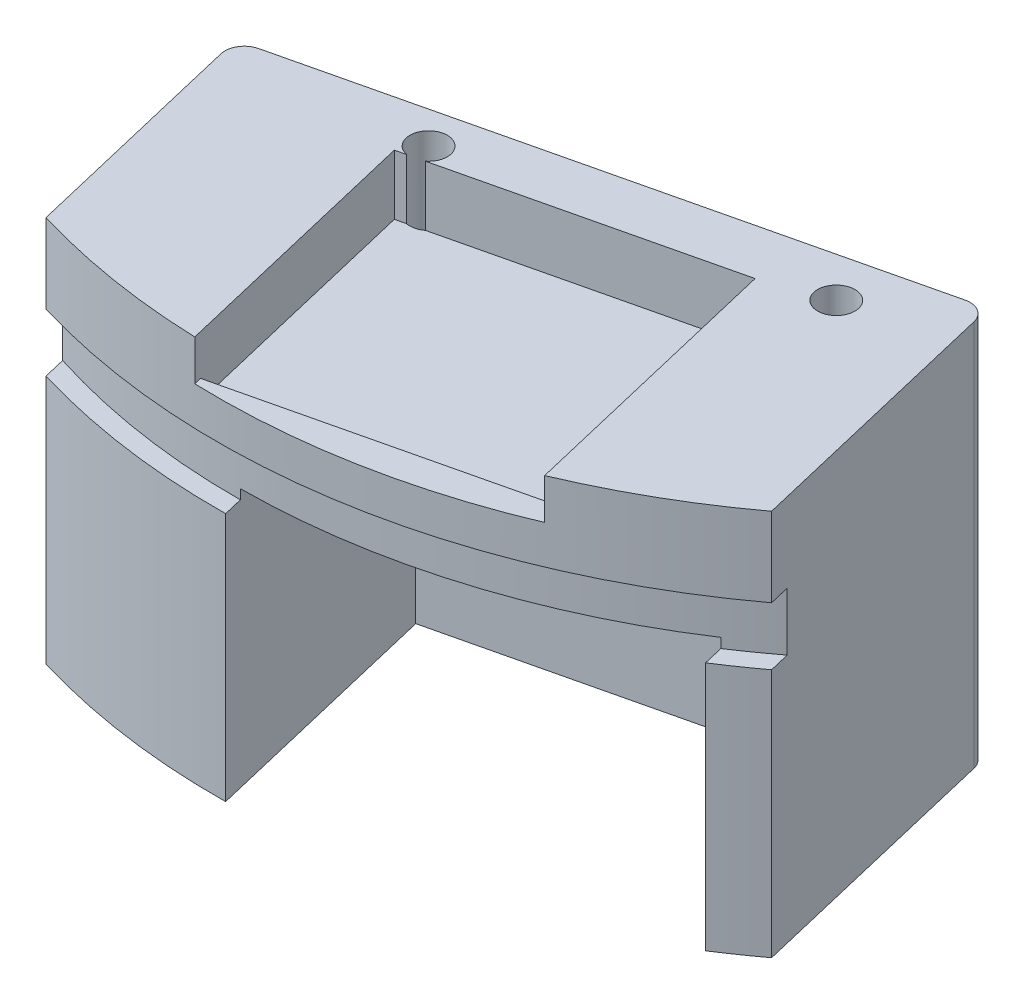
from build123d import *

# Parameters (mm, degrees)
BOSS_EXTRUDE1_DEPTH          = 50.8
CUT_EXTRUDE1_START           = -50.8
CUT_EXTRUDE1_DEPTH           = 34.036
SKETCH10_W                   = 50.546
SKETCH10_H                   = 34.036
CUT_EXTRUDE3_DEPTH           = 20.734311378
CUT_EXTRUDE4_DEPTH           = 2.54
CUT_EXTRUDE5_DEPTH           = 7.874
FILLET1_R                    = 2.54
FILLET2_R                    = 2.54
CUT_EXTRUDE6_DEPTH           = 51.8
F_10_0_1935_DIAMETER_HOLE1_D = 4.9149
FILLET3_R                    = 2.54
CUT_EXTRUDE7_DEPTH           = 5.334
SKETCH18_W                   = 7.62
SKETCH18_H                   = 2.54


with BuildPart() as part:
    # Sketch1 → Boss-Extrude1 (new body)
    with BuildSketch(Plane(origin=(0, 0, 0), x_dir=(1, 0, 0), z_dir=(0, 1, 0))):
        with BuildLine():
            Line((63.017839503, -66.782093), (53.468205472, -26.506342671))
            Line((53.468205472, -26.506342671), (-35.875703335, -47.690346072))
            Line((-35.875703335, -47.690346072), (-26.326069304, -87.966096401))
            ThreePointArc((-26.326069304, -87.966096401), (21.184003401, -89.343908807), (63.017839503, -66.782093))
        make_face()
    extrude(amount=BOSS_EXTRUDE1_DEPTH)

    # Sketch2 → Cut-Extrude1 (cut)
    with BuildSketch(Plane(origin=(0, 50.8, 0), x_dir=(1, 0, 0), z_dir=(0, 1, 0)).offset(CUT_EXTRUDE1_START)):
        Polygon((19.413866358, -81.878324539), (49.046880649, -74.852150244), (42.542248899, -47.418750859), (-6.6401518, -59.08020778), (-0.13552005, -86.513607165), align=None)
    extrude(amount=CUT_EXTRUDE1_DEPTH, mode=Mode.SUBTRACT)

    # Sketch10 → Cut-Extrude3 (cut, through all)
    with BuildSketch(Plane(origin=(19.413866358, 0, 81.878324539), x_dir=(-0.973022607, 0, 0.230709788), z_dir=(-0.230709788, 0, -0.973022607))):
        with Locations((-5.1816, 17.018)):
            Rectangle(SKETCH10_W, SKETCH10_H)
    extrude(amount=-CUT_EXTRUDE3_DEPTH, mode=Mode.SUBTRACT)

    # Sketch11 → Cut-Extrude4 (cut)
    with BuildSketch(Plane.XZ.offset(-34.036)):
        Polygon((4.126655542, 64.024522649), (32.455610184, 56.972208264), (36.418920031, 72.892715879), (8.089965389, 79.945030264), align=None)
    extrude(amount=-CUT_EXTRUDE4_DEPTH, mode=Mode.SUBTRACT)

    # Sketch12 → Cut-Extrude5 (cut)
    with BuildSketch(Plane(origin=(0, 50.8, 0), x_dir=(1, 0, 0), z_dir=(0, 1, 0))):
        Polygon((-3.21042467, -90.775014105), (35.097475372, -81.69196977), (27.186436757, -48.327024572), (-11.121463285, -57.410068908), align=None)
    extrude(amount=-CUT_EXTRUDE5_DEPTH, mode=Mode.SUBTRACT)

    # Fillet1
    fillet1_edges = [part.edges().sort_by_distance(p)[0] for p in [
        (53.468205472, 25.4, 26.506342671),
    ]]
    fillet(fillet1_edges, radius=FILLET1_R)

    # Fillet2
    fillet2_edges = [part.edges().sort_by_distance(p)[0] for p in [
        (-35.875703335, 25.4, 47.690346072),
    ]]
    fillet(fillet2_edges, radius=FILLET2_R)

    # Sketch13 → Cut-Extrude6 (cut, through all)
    with BuildSketch(Plane(origin=(0, 50.8, 0), x_dir=(1, 0, 0), z_dir=(0, 1, 0))):
        Polygon((56.792853338, -82.364213599), (69.150240448, -79.434199297), (54.970742259, -19.631915037), (-50.56134592, -44.654237709), (-47.281500933, -58.487041918), (45.893200136, -36.394733549), align=None)
    extrude(amount=-CUT_EXTRUDE6_DEPTH, mode=Mode.SUBTRACT)

    # #10 (0.1935) Diameter Hole1 (through all)
    with Locations(Plane(origin=(0, 50.8, 0), x_dir=(1, 0, 0), z_dir=(0, 1, 0))):
        with Locations((-9.336173019, -54.694807642), (34.992334459, -45.467652744)):
            Hole(F_10_0_1935_DIAMETER_HOLE1_D / 2)

    # Fillet3
    fillet3_edges = [part.edges().sort_by_distance(p)[0] for p in [
        (-34.059094468, 25.4, 55.35192608),
        (45.893200136, 25.4, 36.394733549),
    ]]
    fillet(fillet3_edges, radius=FILLET3_R)

    # Sketch17 → Cut-Extrude7 (cut)
    with BuildSketch(Plane(origin=(0, 50.8, 0), x_dir=(1, 0, 0), z_dir=(0, 1, 0))):
        Polygon((-5.287837916, -82.013487021), (33.020062126, -72.930442686), (37.24926209, -90.767168294), (-1.058637951, -99.850212629), align=None)
    extrude(amount=-CUT_EXTRUDE7_DEPTH, mode=Mode.SUBTRACT)

    # Sketch18 → Cut-Revolve1 (revolve, cut)
    with BuildSketch(Plane(origin=(0, 0, 0), x_dir=(0, 1, 0), z_dir=(0.999925437, 0, -0.012211508))):
        with Locations((36.576, 90.551)):
            Rectangle(SKETCH18_W, SKETCH18_H)
    revolve(axis=Axis((0, 50.8, 0), (0, -1, 0)), mode=Mode.SUBTRACT)


solid = part.part
